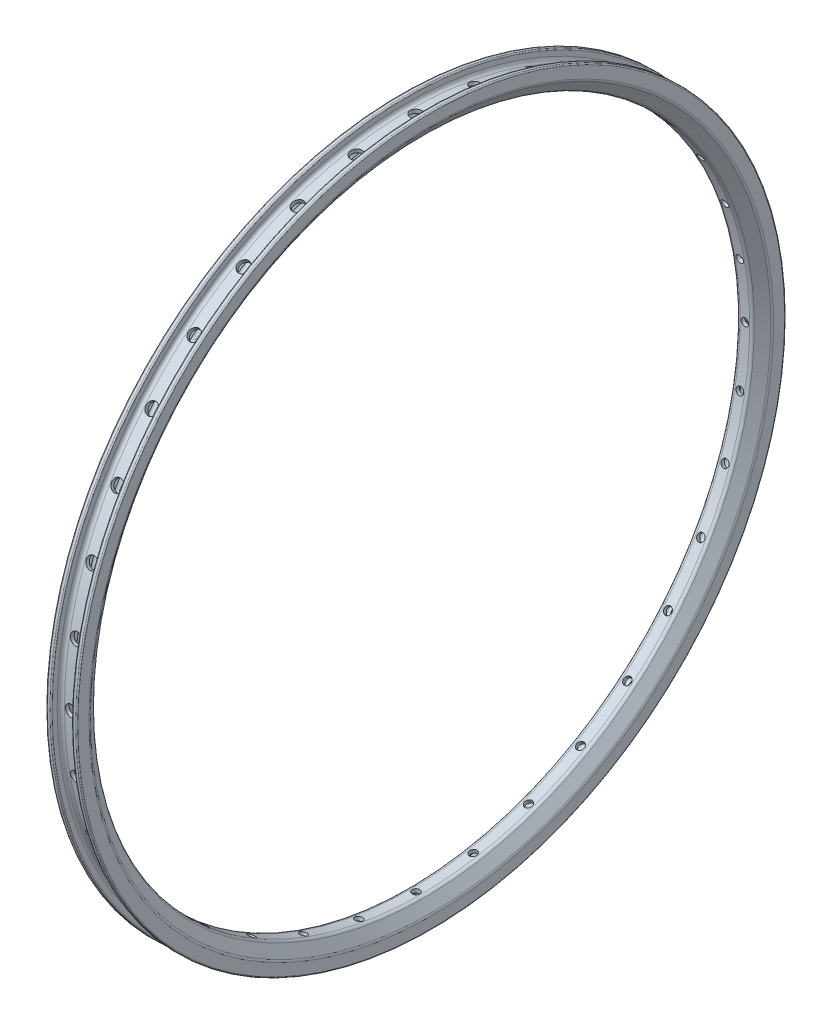
from build123d import *
from build123d.topology import SkipClean

# Parameters (mm, degrees)
REVOLVE1_ANGLE           = 180
REVOLVE1_OTHER_WAY_ANGLE = 180
HOLES_SPOKES_R           = 3.1
CUT_EXTRUDE1_DEPTH       = 26
PATTERN_CIRCULAR_1_COUNT = 36
SKETCH_2_R               = 4.75
CUT_EXTRUDE_1_DEPTH      = 12
PATTERN_CIRCULAR_2_COUNT = 36


with BuildPart() as part:
    # Sketch3 → Revolve1 (revolve)
    with BuildSketch(Plane.XY):
        with BuildLine():
            Line((-3.938033315, 269), (3.938033315, 269))
            ThreePointArc((3.938033315, 269), (5.323464458, 269.339063971), (6.395729077, 270.279612967))
            Line((6.395729077, 270.279612967), (11.957695762, 278.225279659))
            ThreePointArc((11.957695762, 278.225279659), (12.361213666, 279.043748538), (12.5, 279.945666692))
            Line((12.5, 279.945666692), (12.5, 289))
            ThreePointArc((12.5, 289), (12.207106781, 289.707106781), (11.5, 290))
            Line((11.5, 290), (9.5, 290))
            ThreePointArc((9.5, 290), (8.792893219, 289.707106781), (8.5, 289))
            Line((8.5, 289), (8.5, 285))
            ThreePointArc((8.5, 285), (7.621320344, 282.878679656), (5.5, 282))
            Line((5.5, 282), (-5.5, 282))
            ThreePointArc((-5.5, 282), (-7.621320344, 282.878679656), (-8.5, 285))
            Line((-8.5, 285), (-8.5, 289))
            ThreePointArc((-8.5, 289), (-8.792893219, 289.707106781), (-9.5, 290))
            Line((-9.5, 290), (-11.5, 290))
            ThreePointArc((-11.5, 290), (-12.207106781, 289.707106781), (-12.5, 289))
            Line((-12.5, 289), (-12.5, 279.945666692))
            ThreePointArc((-12.5, 279.945666692), (-12.361213666, 279.043748538), (-11.957695762, 278.225279659))
            Line((-11.957695762, 278.225279659), (-6.395729077, 270.279612967))
            ThreePointArc((-6.395729077, 270.279612967), (-5.323464458, 269.339063971), (-3.938033315, 269))
        make_face()
        with BuildLine():
            Line((-4.538033315, 272), (4.538033315, 272))
            ThreePointArc((4.538033315, 272), (5.923464458, 272.339063971), (6.995729077, 273.279612967))
            Line((6.995729077, 273.279612967), (10.457695762, 278.225279659))
            ThreePointArc((10.457695762, 278.225279659), (10.861213666, 279.043748538), (11, 279.945666692))
            Line((11, 279.945666692), (11, 287.6))
            ThreePointArc((11, 287.6), (10.882842712, 287.882842712), (10.6, 288))
            Line((10.6, 288), (10.4, 288))
            ThreePointArc((10.4, 288), (10.117157288, 287.882842712), (10, 287.6))
            Line((10, 287.6), (10, 282))
            ThreePointArc((10, 282), (9.121320344, 279.878679656), (7, 279))
            Line((7, 279), (-7, 279))
            ThreePointArc((-7, 279), (-9.121320344, 279.878679656), (-10, 282))
            Line((-10, 282), (-10, 287.6))
            ThreePointArc((-10, 287.6), (-10.117157288, 287.882842712), (-10.4, 288))
            Line((-10.4, 288), (-10.6, 288))
            ThreePointArc((-10.6, 288), (-10.882842712, 287.882842712), (-11, 287.6))
            Line((-11, 287.6), (-11, 279.945666692))
            ThreePointArc((-11, 279.945666692), (-10.861213666, 279.043748538), (-10.457695762, 278.225279659))
            Line((-10.457695762, 278.225279659), (-6.995729077, 273.279612967))
            ThreePointArc((-6.995729077, 273.279612967), (-5.923464458, 272.339063971), (-4.538033315, 272))
        make_face(mode=Mode.SUBTRACT)
    revolve(axis=Axis((-16.175391887, 0, 0), (1, 0, 0)), revolution_arc=REVOLVE1_ANGLE)

    # Sketch3 → Revolve1 other way (revolve)
    with SkipClean():  # the faces are left unmerged after this step: merging them gives an invalid solid
        with BuildSketch(Plane.XY):
            with BuildLine():
                Line((-3.938033315, 269), (3.938033315, 269))
                ThreePointArc((3.938033315, 269), (5.323464458, 269.339063971), (6.395729077, 270.279612967))
                Line((6.395729077, 270.279612967), (11.957695762, 278.225279659))
                ThreePointArc((11.957695762, 278.225279659), (12.361213666, 279.043748538), (12.5, 279.945666692))
                Line((12.5, 279.945666692), (12.5, 289))
                ThreePointArc((12.5, 289), (12.207106781, 289.707106781), (11.5, 290))
                Line((11.5, 290), (9.5, 290))
                ThreePointArc((9.5, 290), (8.792893219, 289.707106781), (8.5, 289))
                Line((8.5, 289), (8.5, 285))
                ThreePointArc((8.5, 285), (7.621320344, 282.878679656), (5.5, 282))
                Line((5.5, 282), (-5.5, 282))
                ThreePointArc((-5.5, 282), (-7.621320344, 282.878679656), (-8.5, 285))
                Line((-8.5, 285), (-8.5, 289))
                ThreePointArc((-8.5, 289), (-8.792893219, 289.707106781), (-9.5, 290))
                Line((-9.5, 290), (-11.5, 290))
                ThreePointArc((-11.5, 290), (-12.207106781, 289.707106781), (-12.5, 289))
                Line((-12.5, 289), (-12.5, 279.945666692))
                ThreePointArc((-12.5, 279.945666692), (-12.361213666, 279.043748538), (-11.957695762, 278.225279659))
                Line((-11.957695762, 278.225279659), (-6.395729077, 270.279612967))
                ThreePointArc((-6.395729077, 270.279612967), (-5.323464458, 269.339063971), (-3.938033315, 269))
            make_face()
            with BuildLine():
                Line((-4.538033315, 272), (4.538033315, 272))
                ThreePointArc((4.538033315, 272), (5.923464458, 272.339063971), (6.995729077, 273.279612967))
                Line((6.995729077, 273.279612967), (10.457695762, 278.225279659))
                ThreePointArc((10.457695762, 278.225279659), (10.861213666, 279.043748538), (11, 279.945666692))
                Line((11, 279.945666692), (11, 287.6))
                ThreePointArc((11, 287.6), (10.882842712, 287.882842712), (10.6, 288))
                Line((10.6, 288), (10.4, 288))
                ThreePointArc((10.4, 288), (10.117157288, 287.882842712), (10, 287.6))
                Line((10, 287.6), (10, 282))
                ThreePointArc((10, 282), (9.121320344, 279.878679656), (7, 279))
                Line((7, 279), (-7, 279))
                ThreePointArc((-7, 279), (-9.121320344, 279.878679656), (-10, 282))
                Line((-10, 282), (-10, 287.6))
                ThreePointArc((-10, 287.6), (-10.117157288, 287.882842712), (-10.4, 288))
                Line((-10.4, 288), (-10.6, 288))
                ThreePointArc((-10.6, 288), (-10.882842712, 287.882842712), (-11, 287.6))
                Line((-11, 287.6), (-11, 279.945666692))
                ThreePointArc((-11, 279.945666692), (-10.861213666, 279.043748538), (-10.457695762, 278.225279659))
                Line((-10.457695762, 278.225279659), (-6.995729077, 273.279612967))
                ThreePointArc((-6.995729077, 273.279612967), (-5.923464458, 272.339063971), (-4.538033315, 272))
            make_face(mode=Mode.SUBTRACT)
        revolve(axis=Axis((-16.175391887, 0, 0), (-1, 0, 0)), revolution_arc=REVOLVE1_OTHER_WAY_ANGLE)

    # Holes spokes → Cut-Extrude1 (cut)
    with SkipClean():  # the faces are left unmerged after this step: merging them gives an invalid solid
        with BuildSketch(Plane(origin=(0, 290, 0), x_dir=(-1, 0, 0), z_dir=(0, 1, 0))):
            with Locations(Location((0, 0, 0), (0, 0, 90))):
                Circle(HOLES_SPOKES_R)
        cut_extrude1 = extrude(amount=-CUT_EXTRUDE1_DEPTH, mode=Mode.SUBTRACT)

    # Круговой массив1: Cut-Extrude1 ×36 about axis
    with SkipClean():  # the faces are left unmerged after this step: merging them gives an invalid solid
        pattern_circular_1_axis = Axis((-16.175391887, 0, 0), (-1, 0, 0))
        for i in range(1, PATTERN_CIRCULAR_1_COUNT):
            add(cut_extrude1.rotate(pattern_circular_1_axis, i * 360 / PATTERN_CIRCULAR_1_COUNT), mode=Mode.SUBTRACT)

    # Эскиз2 → Вырез-Вытянуть1 (cut)
    with SkipClean():  # the faces are left unmerged after this step: merging them gives an invalid solid
        with BuildSketch(Plane(origin=(0, 290, 0), x_dir=(-1, 0, 0), z_dir=(0, 1, 0))):
            with Locations(Location((0, 0, 0), (0, 0, 90))):
                Circle(SKETCH_2_R)
        cut_extrude_1 = extrude(amount=-CUT_EXTRUDE_1_DEPTH, mode=Mode.SUBTRACT)

    # Круговой массив2: Вырез-Вытянуть1 ×36 about axis
    with SkipClean():  # the faces are left unmerged after this step: merging them gives an invalid solid
        pattern_circular_2_axis = Axis((-16.175391887, 0, 0), (-1, 0, 0))
        for i in range(1, PATTERN_CIRCULAR_2_COUNT):
            add(cut_extrude_1.rotate(pattern_circular_2_axis, i * 360 / PATTERN_CIRCULAR_2_COUNT), mode=Mode.SUBTRACT)


solid = part.part
